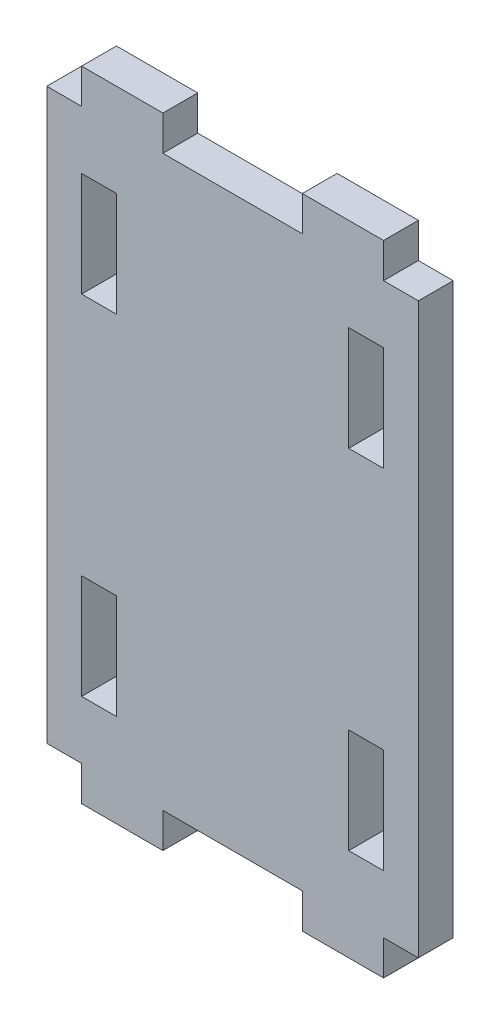
from build123d import *

# Parameters (mm, degrees)
SKETCH_1_W          = 32
SKETCH_1_H          = 55
EXTRUDE_1_DEPTH     = 3
SKETCH_2_W          = 3
SKETCH_2_H          = 3
SKETCH_2_W_2        = 12
CUT_EXTRUDE_1_DEPTH = 4
SKETCH_3_W          = 3
SKETCH_3_H          = 9
CUT_EXTRUDE_2_DEPTH = 4


with BuildPart() as part:
    # 스케치1 → 보스-돌출1 (new body)
    with BuildSketch(Plane.XY):
        with Locations((16, 27.5)):
            Rectangle(SKETCH_1_W, SKETCH_1_H)
    extrude(amount=EXTRUDE_1_DEPTH)

    # 스케치2 → 컷-돌출1 (cut, through all)
    with BuildSketch(Plane.XY.offset(3)):
        with Locations((1.5, 53.5)):
            Rectangle(SKETCH_2_W, SKETCH_2_H)
        with Locations((16, 53.5)):
            Rectangle(SKETCH_2_W_2, SKETCH_2_H)
        with Locations((30.5, 53.5)):
            Rectangle(SKETCH_2_W, SKETCH_2_H)
        with Locations((1.5, 1.5)):
            Rectangle(SKETCH_2_W, SKETCH_2_H)
        with Locations((16, 1.5)):
            Rectangle(SKETCH_2_W_2, SKETCH_2_H)
        with Locations((30.5, 1.5)):
            Rectangle(SKETCH_2_W, SKETCH_2_H)
    extrude(amount=-CUT_EXTRUDE_1_DEPTH, mode=Mode.SUBTRACT)

    # 스케치3 → 컷-돌출2 (cut, through all)
    with BuildSketch(Plane.XY.offset(3)):
        with Locations((4.5, 42.5)):
            Rectangle(SKETCH_3_W, SKETCH_3_H)
        with Locations((27.5, 42.5)):
            Rectangle(SKETCH_3_W, SKETCH_3_H)
        with Locations((27.5, 12.5)):
            Rectangle(SKETCH_3_W, SKETCH_3_H)
        with Locations((4.5, 12.5)):
            Rectangle(SKETCH_3_W, SKETCH_3_H)
    extrude(amount=-CUT_EXTRUDE_2_DEPTH, mode=Mode.SUBTRACT)


solid = part.part
